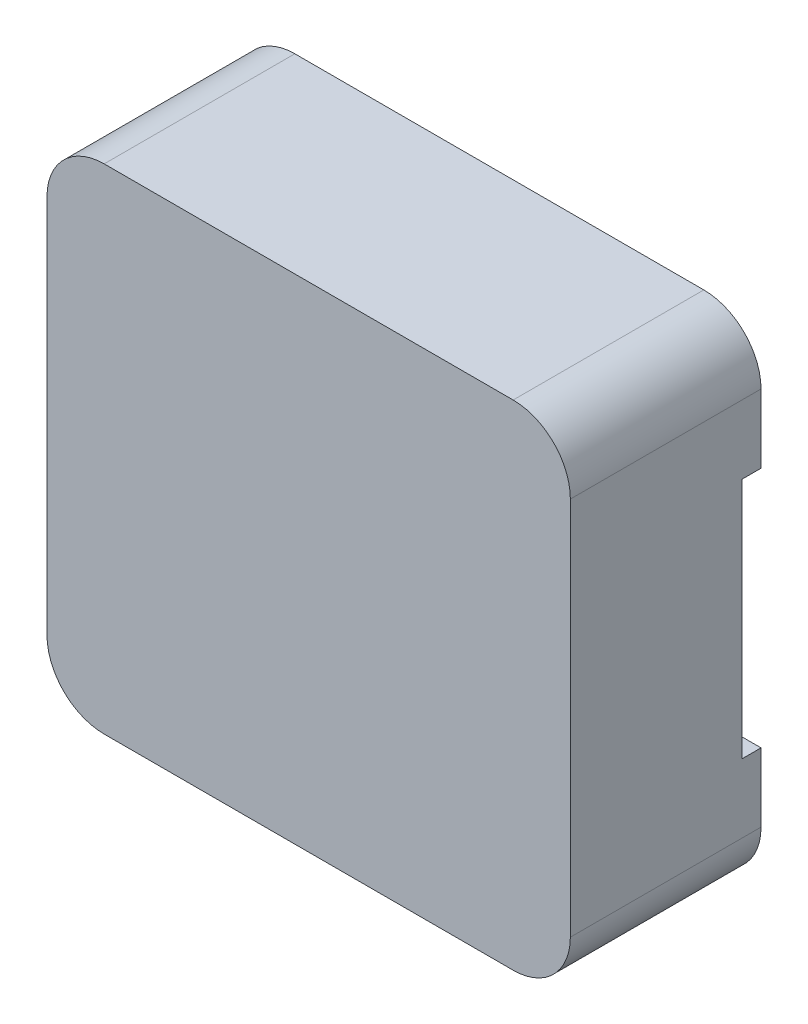
from build123d import *

# Parameters (mm, degrees)
ESQUISSE1_W             = 5.49
ESQUISSE1_H             = 5.18
BOSS_EXTRU_1_DEPTH      = 2
CONG_1_R                = 0.6
ESQUISSE2_W             = 1.02
ESQUISSE2_H             = 2.54
ENL_V_MAT_EXTRU_1_DEPTH = 0.2


with BuildPart() as part:
    # Esquisse1 → Boss.-Extru.1 (new body)
    with BuildSketch(Plane.XY):
        with Locations((2.745, 2.59)):
            Rectangle(ESQUISSE1_W, ESQUISSE1_H)
    extrude(amount=BOSS_EXTRU_1_DEPTH)

    # Congé1
    cong_1_edges = [part.edges().sort_by_distance(p)[0] for p in [
        (0, 5.18, 1),
        (5.49, 5.18, 1),
        (5.49, 0, 1),
        (0, 0, 1),
    ]]
    fillet(cong_1_edges, radius=CONG_1_R)

    # Esquisse2 → Enlèv. mat.-Extru.1 (cut)
    with BuildSketch(Plane(origin=(0, 0, 0), x_dir=(-1, 0, 0), z_dir=(0, 0, -1))):
        with Locations((-0.51, 2.59)):
            Rectangle(ESQUISSE2_W, ESQUISSE2_H)
        with Locations((-4.98, 2.59)):
            Rectangle(ESQUISSE2_W, ESQUISSE2_H)
    extrude(amount=-ENL_V_MAT_EXTRU_1_DEPTH, mode=Mode.SUBTRACT)


solid = part.part
